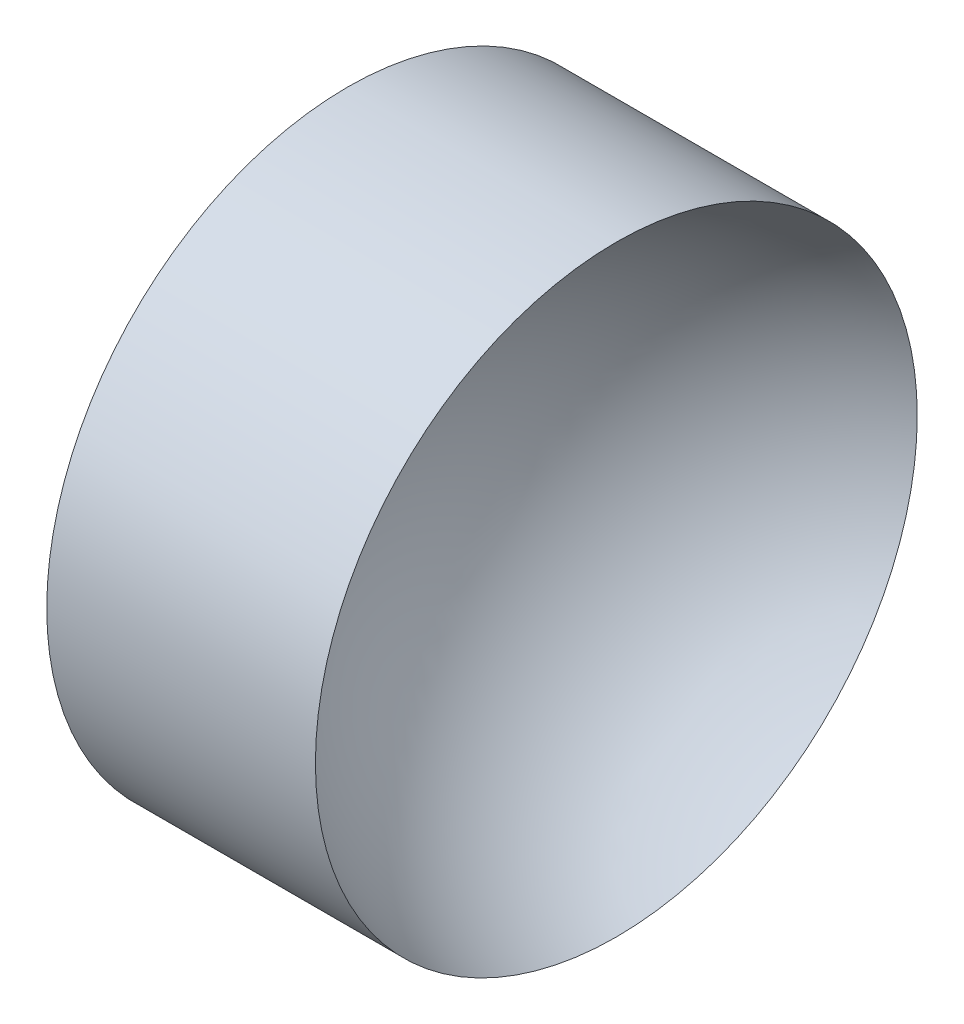
from build123d import *


with BuildPart() as part:
    # 草图1 → 旋转1 (revolve)
    with BuildSketch(Plane.XY, mode=Mode.PRIVATE) as revolve_1_sk:
        with BuildLine():
            Line((57.532337053, 32.610768129), (57.532337053, 45.110768129))
            Line((57.532337053, 45.110768129), (68.692337053, 45.110768129))
            ThreePointArc((68.692337053, 45.110768129), (62.067471783, 40.359245399), (59.532337053, 32.610768129))
            Line((59.532337053, 32.610768129), (57.532337053, 32.610768129))
        make_face()
    revolve(revolve_1_sk.sketch.rotate(Axis((56.10091508, 32.610768129, 0), (1, 0, 0)), 180), axis=Axis((56.10091508, 32.610768129, 0), (1, 0, 0)))  # turned: the seam where the file's is


solid = part.part
